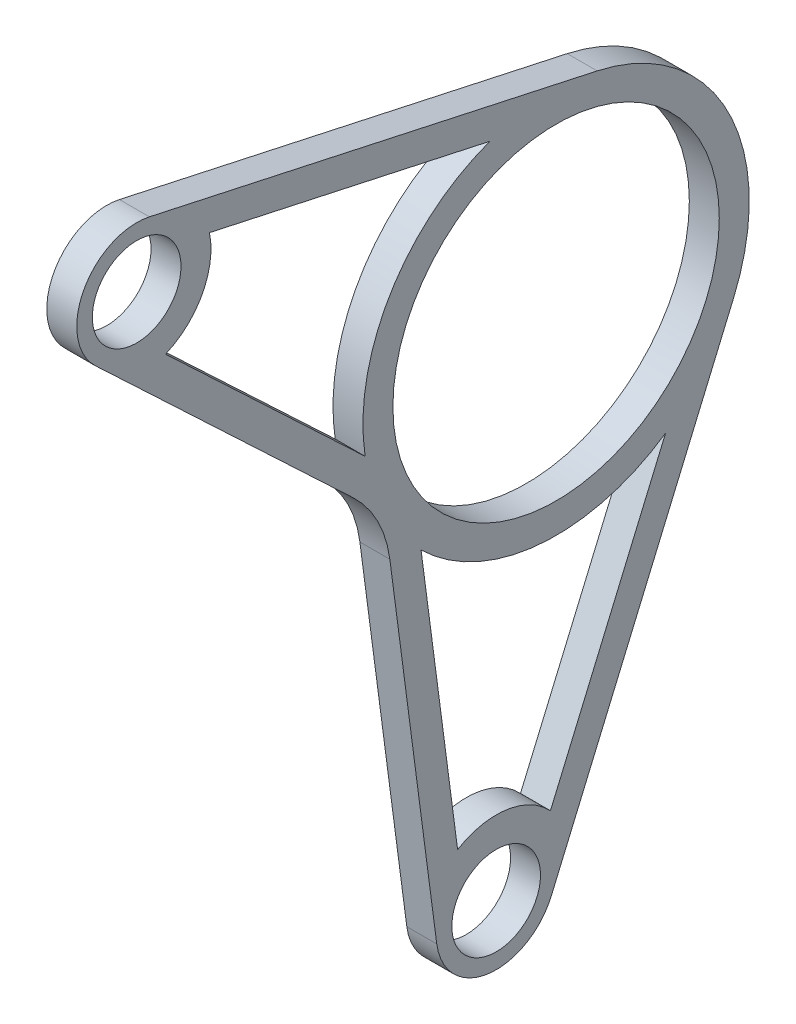
from build123d import *

# Parameters (mm, degrees)
SKETCH1_R           = 9.398
SKETCH1_R_2         = 34.589431616
BOSS_EXTRUDE1_DEPTH = 3.175
FILLET1_R           = 25.4
CUT_EXTRUDE1_DEPTH  = 7.35


with BuildPart() as part:
    # Sketch1 → Boss-Extrude1 (new body, symmetric)
    with BuildSketch(Plane(origin=(-101.6, 0, 0), x_dir=(0, 0, -1), z_dir=(1, 0, 0))):
        with BuildLine():
            Line((181.785515067, 280.321615274), (242.984426747, 222.593234225))
            Line((242.984426747, 222.593234225), (254.108513166, 138.043359025))
            ThreePointArc((254.108513166, 138.043359025), (264.972075139, 127.118097295), (278.378708009, 134.710232547))
            Line((278.378708009, 134.710232547), (317.047217946, 225.215098942))
            ThreePointArc((317.047217946, 225.215098942), (315.782704, 260.070612955), (288.110795268, 281.301988787))
            Line((288.110795268, 281.301988787), (193.202213869, 301.969191763))
            ThreePointArc((193.202213869, 301.969191763), (179.266512438, 295.48442041), (181.785515067, 280.321615274))
        make_face()
        with Locations((190.5, 289.56)):
            Circle(SKETCH1_R, mode=Mode.SUBTRACT)
        with Locations((279.4, 241.3)):
            Circle(SKETCH1_R_2, mode=Mode.SUBTRACT)
        with Locations((266.7, 139.7)):
            Circle(SKETCH1_R, mode=Mode.SUBTRACT)
    extrude(amount=BOSS_EXTRUDE1_DEPTH, both=True)

    # Fillet1
    fillet1_edges = [part.edges().sort_by_distance(p)[0] for p in [
        (-101.6, 222.593234225, -242.984426747),
    ]]
    fillet(fillet1_edges, radius=FILLET1_R)

    # Sketch2 → Cut-Extrude1 (cut, through all)
    with BuildSketch(Plane(origin=(-98.425, 0, 0), x_dir=(0, 0, -1), z_dir=(1, 0, 0))):
        with BuildLine():
            Line((196.625780281, 275.052266892), (238.924841277, 235.151944416))
            ThreePointArc((238.924841277, 235.151944416), (244.181424008, 262.17316378), (265.361199141, 279.757107685))
            Line((265.361199141, 279.757107685), (205.932122543, 292.698327232))
            ThreePointArc((205.932122543, 292.698327232), (204.429524577, 282.213718691), (196.625780281, 275.052266892))
        make_face()
        with BuildLine():
            Line((250.779296509, 212.027275618), (258.524425256, 153.159549829))
            ThreePointArc((258.524425256, 153.159549829), (268.842626828, 155.301559354), (278.201366063, 150.45723397))
            Line((278.201366063, 150.45723397), (302.603477212, 207.571144307))
            ThreePointArc((302.603477212, 207.571144307), (275.892741569, 200.511077492), (250.779296509, 212.027275618))
        make_face()
    extrude(amount=-CUT_EXTRUDE1_DEPTH, mode=Mode.SUBTRACT)


solid = part.part
